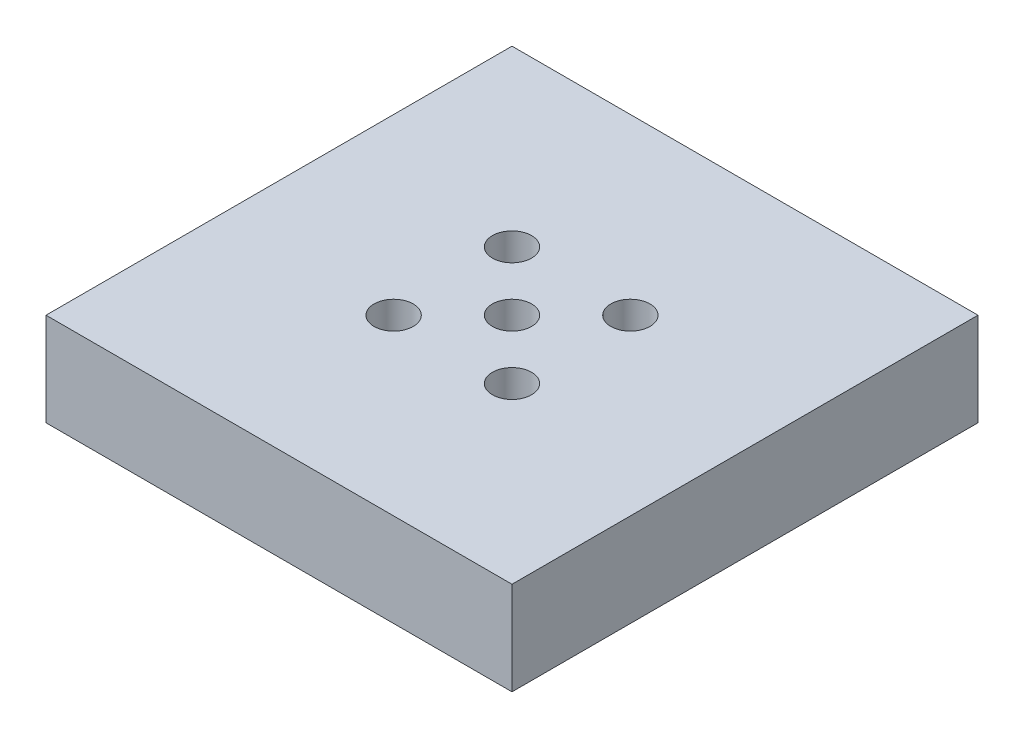
from build123d import *

# Parameters (mm, degrees)
SKETCH2_W           = 50
SKETCH2_H           = 50
BOSS_EXTRUDE1_DEPTH = 10
SKETCH4_R           = 2.1
CUT_EXTRUDE1_DEPTH  = 4.57
SKETCH5_W           = 20
SKETCH5_H           = 20
CUT_EXTRUDE2_DEPTH  = 5.43


with BuildPart() as part:
    # Sketch2 → Boss-Extrude1 (new body)
    with BuildSketch(Plane(origin=(0, 0, 0), x_dir=(1, 0, 0), z_dir=(0, 1, 0))):
        Rectangle(SKETCH2_W, SKETCH2_H)
    extrude(amount=BOSS_EXTRUDE1_DEPTH)

    # Sketch4 → Cut-Extrude1 (cut)
    with BuildSketch(Plane(origin=(0, 10, 0), x_dir=(1, 0, 0), z_dir=(0, 1, 0))):
        Circle(SKETCH4_R)
        with Locations((6.35, 6.35)):
            Circle(SKETCH4_R)
        with Locations((-6.35, 6.35)):
            Circle(SKETCH4_R)
        with Locations((-6.35, -6.35)):
            Circle(SKETCH4_R)
        with Locations((6.35, -6.35)):
            Circle(SKETCH4_R)
    extrude(amount=-CUT_EXTRUDE1_DEPTH, mode=Mode.SUBTRACT)

    # Sketch5 → Cut-Extrude2 (cut)
    with BuildSketch(Plane.XZ):
        Rectangle(SKETCH5_W, SKETCH5_H)
    extrude(amount=-CUT_EXTRUDE2_DEPTH, mode=Mode.SUBTRACT)


solid = part.part
